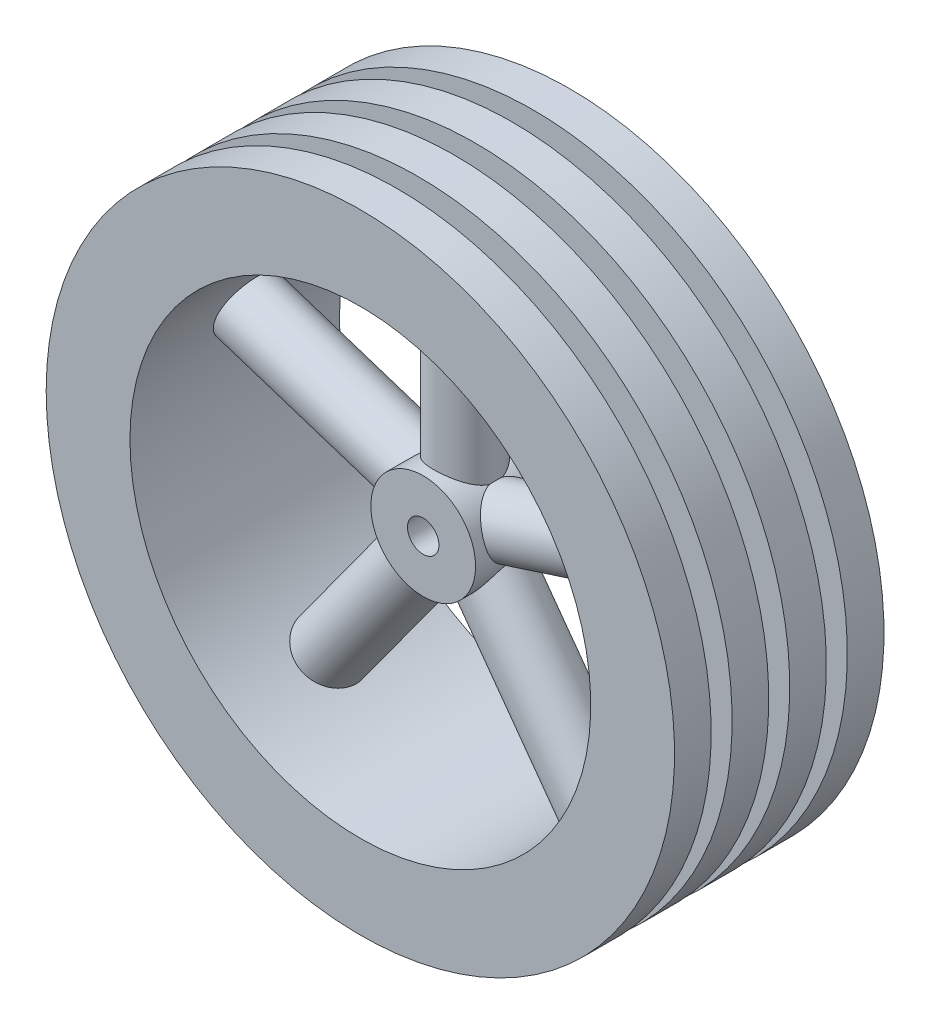
from build123d import *

# Parameters (mm, degrees)
SKETCH_1_R                       = 5
SKETCH_1_R_2                     = 1.5
EXTRUDE_1_DEPTH                  = 20
EXTRUDE_2_REACH                  = 57.353
EXTRUDE_2_END_RADIUS             = 22
SKETCH_5_R                       = 3
EXTRUDE_2_DIRECTION_2_REACH      = 57.353
EXTRUDE_2_DIRECTION_2_END_RADIUS = 5
PATTERN_CIRCULAR_1_COUNT         = 5
SKETCH_7_R                       = 5
CUT_EXTRUDE_1_DEPTH              = 6


with BuildPart() as part:
    # 草圖1 → 填料-伸長1 (new body)
    with BuildSketch(Plane.XY):
        Circle(SKETCH_1_R)
        Circle(SKETCH_1_R_2, mode=Mode.SUBTRACT)
    extrude(amount=EXTRUDE_1_DEPTH)



with BuildPart() as body_2:
    # 草圖2 → 旋轉2 (revolve)
    with BuildSketch(Plane(origin=(0, 0, 0), x_dir=(1, 0, 0), z_dir=(0, 1, 0))):
        Polygon((-30, 0), (-22, 0), (-22, -20), (-30, -20), (-30, -16.5), (-25, -16.5), (-25, -14.5), (-30, -14.5), (-30, -11), (-25, -11), (-25, -9), (-30, -9), (-30, -5.5), (-25, -5.5), (-25, -3.5), (-30, -3.5), align=None)
    revolve(axis=Axis((0, 0, -16.060558383), (0, 0, 1)))


with BuildPart() as part_1:
    add(part.part)

    add(body_2.part)  # 填料-伸長2 merges body 2
    # 填料-伸長2: up to this cylinder (the profile starts inside it)
    extrude_2_end = Plane(origin=(0, 0, 10), z_dir=(0, 0, -1)) * Cylinder(EXTRUDE_2_END_RADIUS, 159.706, mode=Mode.PRIVATE)
    # 草圖5 → 填料-伸長2 (add, up to the surface)
    with BuildSketch(Plane(origin=(0, 12, 0), x_dir=(1, 0, 0), z_dir=(0, 1, 0)), mode=Mode.PRIVATE) as extrude_2_sk1:
        with Locations(Location((0, -10, 0), (0, 0, 270))):
            Circle(SKETCH_5_R)
    extrude_2_tool1 = extrude(extrude_2_sk1.sketch, amount=EXTRUDE_2_REACH, mode=Mode.PRIVATE) & extrude_2_end
    extrude_2 = extrude_2_tool1.solids().sort_by_distance((0, 12, 10))[0]
    add(extrude_2)

    # 填料-伸長2 direction 2: up to this cylinder (the profile starts outside it)
    extrude_2_direction_2_end = Plane(origin=(0, 0, 10), z_dir=(0, 0, -1)) * Cylinder(EXTRUDE_2_DIRECTION_2_END_RADIUS, 125.706, mode=Mode.PRIVATE)
    # 草圖5 → 填料-伸長2 direction 2 (add, up to the surface)
    with BuildSketch(Plane(origin=(0, 12, 0), x_dir=(1, 0, 0), z_dir=(0, 1, 0)), mode=Mode.PRIVATE) as extrude_2_direction_2_sk1:
        with Locations(Location((0, -10, 0), (0, 0, 270))):
            Circle(SKETCH_5_R)
    extrude_2_direction_2_tool1 = extrude(extrude_2_direction_2_sk1.sketch, amount=-EXTRUDE_2_DIRECTION_2_REACH, mode=Mode.PRIVATE) - extrude_2_direction_2_end
    extrude_2_direction_2 = extrude_2_direction_2_tool1.solids().sort_by_distance((0, 12, 10))[0]
    add(extrude_2_direction_2)
    extrude_2 = extrude_2 + extrude_2_direction_2  # both directions under the feature's name, for the pattern or mirror that repeats it

    # 環狀複製排列1: 填料-伸長2 ×5 about axis
    pattern_circular_1_axis = Axis((0, 0, 20), (0, 0, -1))
    for i in range(1, PATTERN_CIRCULAR_1_COUNT):
        add(extrude_2.rotate(pattern_circular_1_axis, i * 360 / PATTERN_CIRCULAR_1_COUNT))

    # 草圖7 → 除料-伸長1 (cut)
    with BuildSketch(Plane.XY.offset(20)):
        with Locations(Location((0, 0, 0), (0, 0, 197.999718302))):
            Circle(SKETCH_7_R)
    extrude(amount=-CUT_EXTRUDE_1_DEPTH, mode=Mode.SUBTRACT)


solid = part_1.part
